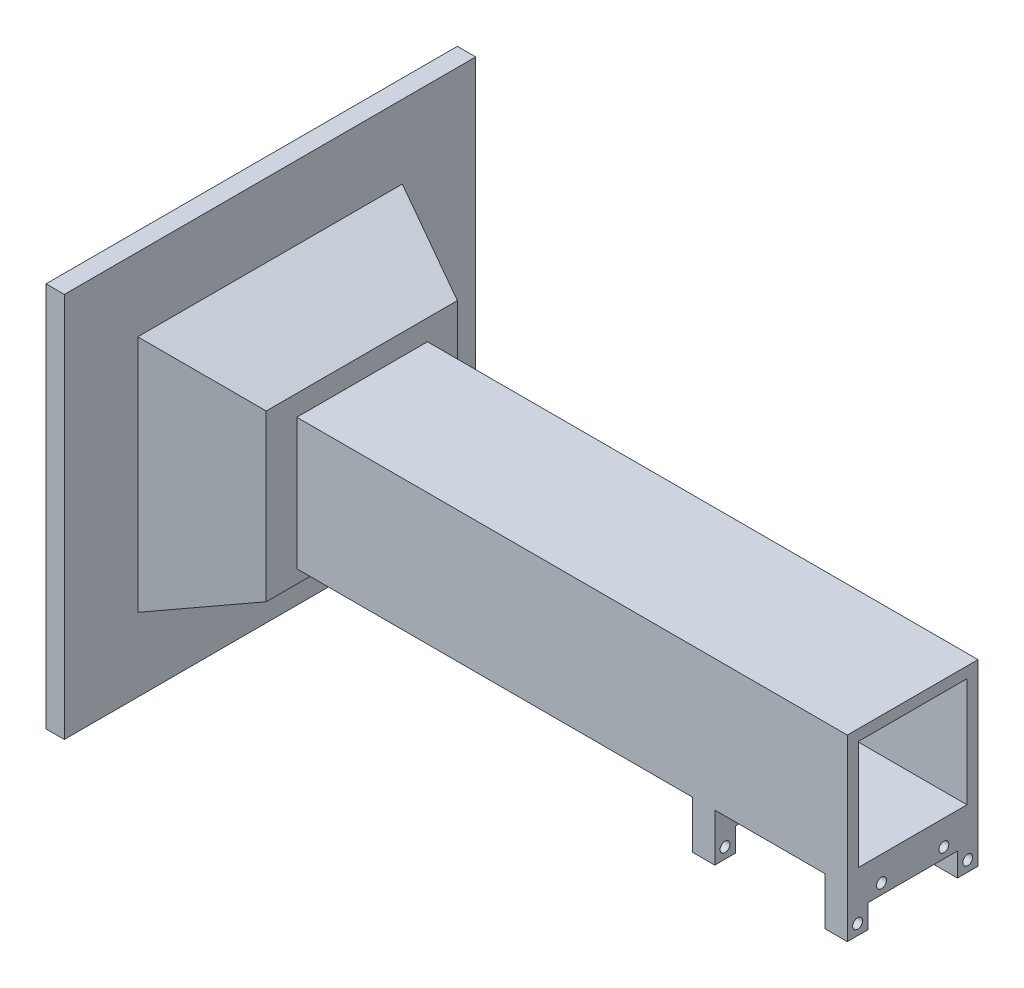
from build123d import *

# Parameters (mm, degrees)
SKETCH1_W                = 42.25
SKETCH1_H                = 35.6
BOSS_EXTRUDE1_DEPTH      = 2
SKETCH2_W                = 2
SKETCH2_H                = 35.6
BOSS_EXTRUDE2_DEPTH      = 50
SKETCH1_2_W              = 42.25
SKETCH1_2_H              = 35.6
CUT_EXTRUDE6_DEPTH       = 20
SKETCH8_W                = 42.25
SKETCH8_H                = 35.6
BOSS_EXTRUDE3_DEPTH      = 2
SKETCH9_W                = 35.6
SKETCH9_H                = 13
BOSS_EXTRUDE4_DEPTH      = 42.25
SKETCH12_W               = 30
SKETCH12_H               = 13
CUT_EXTRUDE9_DEPTH       = 36.6
SKETCH13_W               = 24.4
SKETCH13_H               = 13
CUT_EXTRUDE10_DEPTH      = 37.125
CUT_EXTRUDE10_DEPTH_BACK = 7.125
SKETCH15_R               = 1.35
CUT_EXTRUDE11_DEPTH      = 43.25
SKETCH16_W               = 35.6
SKETCH16_H               = 35.754688938
BOSS_EXTRUDE5_DEPTH      = 150
SKETCH18_W               = 112.087725711
SKETCH18_H               = 105.02156137
BOSS_EXTRUDE6_DEPTH      = 5
SKETCH20_W               = 72.087725711
SKETCH20_H               = 65.02156137
SKETCH17_W               = 52.087725711
SKETCH17_H               = 45.02156137
SKETCH21_W               = 29.6
SKETCH21_H               = 29.754688938
CUT_EXTRUDE13_DEPTH      = 150
SKETCH25_W               = 24.4
SKETCH25_H               = 6.6
BOSS_EXTRUDE9_DEPTH      = 6.125
SKETCH26_W               = 24.4
SKETCH26_H               = 6.6
BOSS_EXTRUDE10_DEPTH     = 6.125
SKETCH27_R               = 1.35
CUT_EXTRUDE15_DEPTH      = 42.25


with BuildPart() as part:
    # Sketch1 → Boss-Extrude1 (new body)
    with BuildSketch(Plane(origin=(0, 0, 0), x_dir=(1, 0, 0), z_dir=(0, 1, 0))):
        Rectangle(SKETCH1_W, SKETCH1_H)
    extrude(amount=BOSS_EXTRUDE1_DEPTH)

    # Sketch2 → Boss-Extrude2 (add)
    with BuildSketch(Plane(origin=(0, 2, 0), x_dir=(1, 0, 0), z_dir=(0, 1, 0))):
        with Locations((-20.125, 0)):
            Rectangle(SKETCH2_W, SKETCH2_H)
        with Locations((20.125, 0)):
            Rectangle(SKETCH2_W, SKETCH2_H)
    extrude(amount=BOSS_EXTRUDE2_DEPTH)

    # Sketch1_2 → Cut-Extrude6 (cut)
    with BuildSketch(Plane(origin=(0, 0, 0), x_dir=(1, 0, 0), z_dir=(0, 1, 0))):
        Rectangle(SKETCH1_2_W, SKETCH1_2_H)
    extrude(amount=CUT_EXTRUDE6_DEPTH, mode=Mode.SUBTRACT)

    # Sketch8 → Boss-Extrude3 (add)
    with BuildSketch(Plane.XZ.offset(-20)):
        Rectangle(SKETCH8_W, SKETCH8_H)
    extrude(amount=BOSS_EXTRUDE3_DEPTH)

    # Sketch9 → Boss-Extrude4 (add)
    with BuildSketch(Plane(origin=(21.125, 0, 0), x_dir=(0, 0, -1), z_dir=(1, 0, 0))):
        with Locations((0, 11.5)):
            Rectangle(SKETCH9_W, SKETCH9_H)
    extrude(amount=-BOSS_EXTRUDE4_DEPTH)

    # Sketch12 → Cut-Extrude9 (cut, through all)
    with BuildSketch(Plane(origin=(0, 0, -17.8), x_dir=(-1, 0, 0), z_dir=(0, 0, -1))):
        with Locations((0, 11.5)):
            Rectangle(SKETCH12_W, SKETCH12_H)
    extrude(amount=-CUT_EXTRUDE9_DEPTH, mode=Mode.SUBTRACT)

    # Sketch13 → Cut-Extrude10 (cut, two sides)
    with BuildSketch(Plane.ZY.offset(-15)) as cut_extrude10_sk:
        with Locations((0, 11.5)):
            Rectangle(SKETCH13_W, SKETCH13_H)
    extrude(amount=CUT_EXTRUDE10_DEPTH, mode=Mode.SUBTRACT)
    extrude(cut_extrude10_sk.sketch, amount=-CUT_EXTRUDE10_DEPTH_BACK, mode=Mode.SUBTRACT)

    # Sketch15 → Cut-Extrude11 (cut, through all)
    with BuildSketch(Plane.ZY.offset(21.125)):
        with Locations((-15, 7.9)):
            Circle(SKETCH15_R)
        with Locations((15, 7.9)):
            Circle(SKETCH15_R)
    extrude(amount=-CUT_EXTRUDE11_DEPTH, mode=Mode.SUBTRACT)

    # Sketch16 → Boss-Extrude5 (add)
    with BuildSketch(Plane(origin=(21.125, 0, 0), x_dir=(0, 0, -1), z_dir=(1, 0, 0))):
        with Locations((0, 35.877344469)):
            Rectangle(SKETCH16_W, SKETCH16_H)
    extrude(amount=-BOSS_EXTRUDE5_DEPTH)



with BuildPart() as body_2:
    # Sketch18 → Boss-Extrude6 (new body)
    with BuildSketch(Plane.ZY.offset(158.875)):
        with Locations((0.100945205, 36.893036207)):
            Rectangle(SKETCH18_W, SKETCH18_H)
    extrude(amount=-BOSS_EXTRUDE6_DEPTH)


with BuildPart() as part_1:
    add(part.part)

    add(body_2.part)  # Loft1 merges body 2
    # Sketch20 → Loft1 section 0
    with BuildSketch(Plane(origin=(-153.875, 0, 0), x_dir=(0, 0, -1), z_dir=(1, 0, 0))):
        with Locations((-0.100945205, 36.893036207)):
            Rectangle(SKETCH20_W, SKETCH20_H)
    # Sketch17 → Loft1 section 1
    with BuildSketch(Plane.ZY.offset(128.875)):
        with Locations((0.100945205, 36.893036207)):
            Rectangle(SKETCH17_W, SKETCH17_H)
    loft()

    # Sketch21 → Cut-Extrude13 (cut)
    with BuildSketch(Plane(origin=(21.125, 0, 0), x_dir=(0, 0, -1), z_dir=(1, 0, 0))):
        with Locations((0, 35.877344469)):
            Rectangle(SKETCH21_W, SKETCH21_H)
    extrude(amount=-CUT_EXTRUDE13_DEPTH, mode=Mode.SUBTRACT)

    # Sketch25 → Boss-Extrude9 (add)
    with BuildSketch(Plane(origin=(21.125, 0, 0), x_dir=(0, 0, -1), z_dir=(1, 0, 0))):
        with Locations((0, 14.7)):
            Rectangle(SKETCH25_W, SKETCH25_H)
    extrude(amount=-BOSS_EXTRUDE9_DEPTH)

    # Sketch26 → Boss-Extrude10 (add)
    with BuildSketch(Plane(origin=(-15, 0, 0), x_dir=(0, 0, -1), z_dir=(1, 0, 0))):
        with Locations((0, 14.7)):
            Rectangle(SKETCH26_W, SKETCH26_H)
    extrude(amount=-BOSS_EXTRUDE10_DEPTH)

    # Sketch27 → Cut-Extrude15 (cut)
    with BuildSketch(Plane(origin=(21.125, 0, 0), x_dir=(0, 0, -1), z_dir=(1, 0, 0))):
        with Locations((8.5, 14.2)):
            Circle(SKETCH27_R)
        with Locations((-8.5, 14.2)):
            Circle(SKETCH27_R)
    extrude(amount=-CUT_EXTRUDE15_DEPTH, mode=Mode.SUBTRACT)


solid = part_1.part
